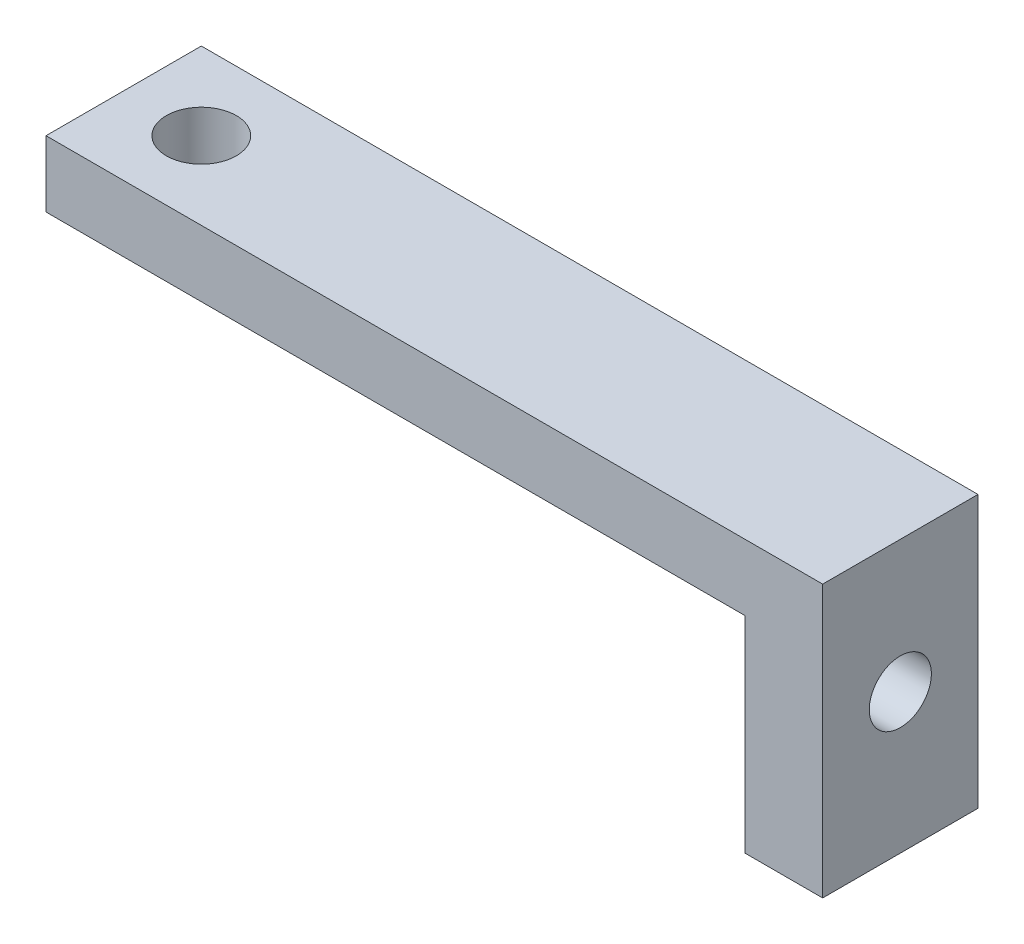
from build123d import *

# Parameters (mm, degrees)
BOSS_EXTRUDE1_DEPTH = 5.08
SKETCH2_R           = 1.143
CUT_EXTRUDE1_DEPTH  = 5.08
SKETCH3_R           = 1.016
CUT_EXTRUDE2_DEPTH  = 5.08


with BuildPart() as part:
    # Sketch1 → Boss-Extrude1 (new body)
    with BuildSketch(Plane.XY):
        Polygon((-75.921062447, -12.572076515), (-75.921062447, -10.410151662), (-50.521062447, -10.410151662), (-50.521062447, -19.300151662), (-53.061062447, -19.300151662), (-53.061062447, -12.572076515), align=None)
    extrude(amount=BOSS_EXTRUDE1_DEPTH)

    # Sketch2 → Cut-Extrude1 (cut)
    with BuildSketch(Plane(origin=(0, -10.410151662, 0), x_dir=(1, 0, 0), z_dir=(0, 1, 0))):
        with Locations((-73.381062447, -2.54)):
            Circle(SKETCH2_R)
    extrude(amount=-CUT_EXTRUDE1_DEPTH, mode=Mode.SUBTRACT)

    # Sketch3 → Cut-Extrude2 (cut)
    with BuildSketch(Plane(origin=(-50.521062447, 0, 0), x_dir=(0, 0, -1), z_dir=(1, 0, 0))):
        with Locations((-2.54, -14.728151662)):
            Circle(SKETCH3_R)
    extrude(amount=-CUT_EXTRUDE2_DEPTH, mode=Mode.SUBTRACT)


solid = part.part
